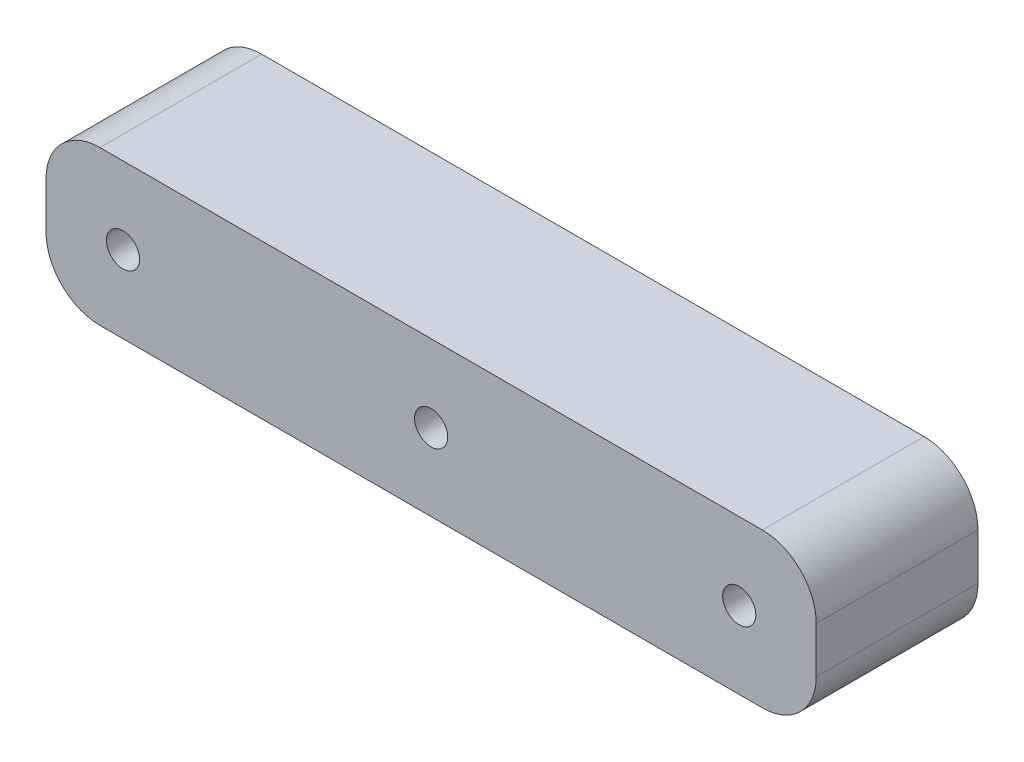
from build123d import *

# Parameters (mm, degrees)
SKETCH1_W           = 100
SKETCH1_H           = 20
SKETCH1_R           = 2.15
BOSS_EXTRUDE1_DEPTH = 21
FILLET1_R           = 7


with BuildPart() as part:
    # Sketch1 → Boss-Extrude1 (new body)
    with BuildSketch(Plane.XY):
        with Locations((50, -10)):
            Rectangle(SKETCH1_W, SKETCH1_H)
        with Locations((10, -10)):
            Circle(SKETCH1_R, mode=Mode.SUBTRACT)
        with Locations((90, -10)):
            Circle(SKETCH1_R, mode=Mode.SUBTRACT)
        with Locations((50, -10)):
            Circle(SKETCH1_R, mode=Mode.SUBTRACT)
    extrude(amount=BOSS_EXTRUDE1_DEPTH)

    # Fillet1
    fillet1_edges = [part.edges().sort_by_distance(p)[0] for p in [
        (0, 0, 10.5),
        (100, 0, 10.5),
        (100, -20, 10.5),
        (0, -20, 10.5),
    ]]
    fillet(fillet1_edges, radius=FILLET1_R)


solid = part.part
